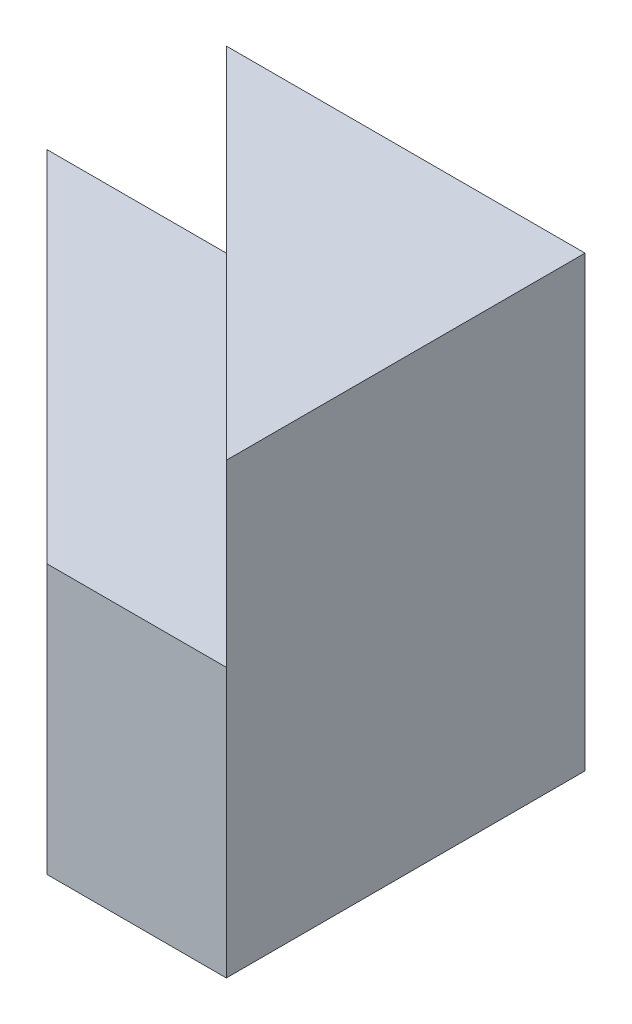
from build123d import *

# Parameters (mm, degrees)
SKETCH1_W           = 6
SKETCH1_H           = 4
BOSS_EXTRUDE1_DEPTH = 3
BOSS_EXTRUDE2_DEPTH = 2
CUT_EXTRUDE1_DEPTH  = 10


with BuildPart() as part:
    # Sketch1 → Boss-Extrude1 (new body)
    with BuildSketch(Plane(origin=(0, 0, 0), x_dir=(1, 0, 0), z_dir=(0, 1, 0))):
        with Locations((3, 2)):
            Rectangle(SKETCH1_W, SKETCH1_H)
    extrude(amount=BOSS_EXTRUDE1_DEPTH)

    # Sketch3 → Boss-Extrude2 (add)
    with BuildSketch(Plane(origin=(0, 3, 0), x_dir=(1, 0, 0), z_dir=(0, 1, 0))):
        Polygon((6, 4), (6, 0), (2, 4), align=None)
    extrude(amount=BOSS_EXTRUDE2_DEPTH)

    # Sketch4 → Cut-Extrude1 (cut)
    with BuildSketch(Plane(origin=(0, 3, 0), x_dir=(1, 0, 0), z_dir=(0, 1, 0))):
        Polygon((4, 0), (0, 4), (0, 0), align=None)
    extrude(amount=-CUT_EXTRUDE1_DEPTH, mode=Mode.SUBTRACT)


solid = part.part
